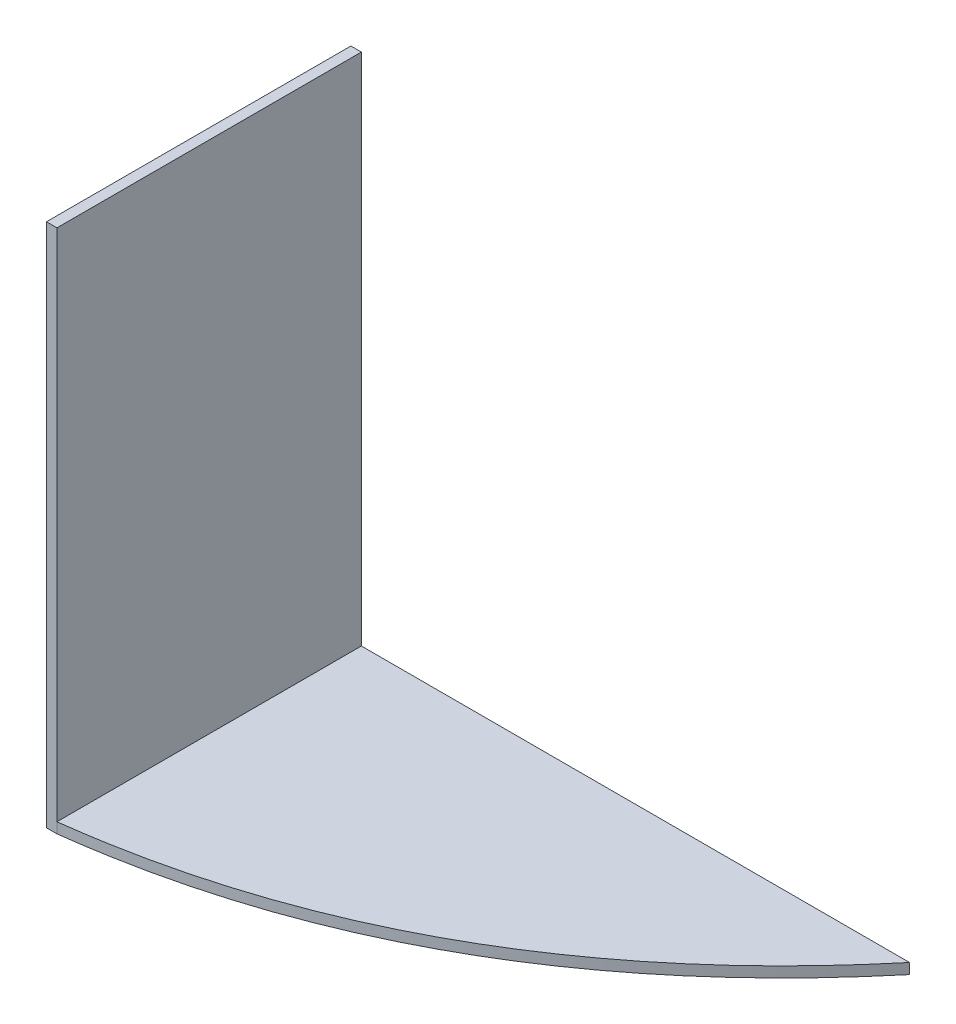
from build123d import *

# Parameters (mm, degrees)
SKETCH1_W           = 2
SKETCH1_H           = 100
BOSS_EXTRUDE1_DEPTH = 58
BOSS_EXTRUDE2_DEPTH = 2


with BuildPart() as part:
    # Sketch1 → Boss-Extrude1 (new body)
    with BuildSketch(Plane.XY):
        with Locations((-0.084337349, -26.626506024)):
            Rectangle(SKETCH1_W, SKETCH1_H)
    extrude(amount=BOSS_EXTRUDE1_DEPTH)

    # Sketch2 → Boss-Extrude2 (add)
    with BuildSketch(Plane.XZ.offset(76.626506024)):
        with BuildLine():
            Line((0.915662651, 58), (-1.084337349, 58))
            Line((-1.084337349, 58), (-1.084337349, 0))
            Line((-1.084337349, 0), (105.357714941, 0))
            add(Edge.make_bspline(
                [(0.915662651, 58), (63.617404925, 50.187924703), (105.357714941, 0)],
                knots=[0, 0, 0, 1, 1, 1], degree=2))
        make_face()
    extrude(amount=-BOSS_EXTRUDE2_DEPTH)


solid = part.part
